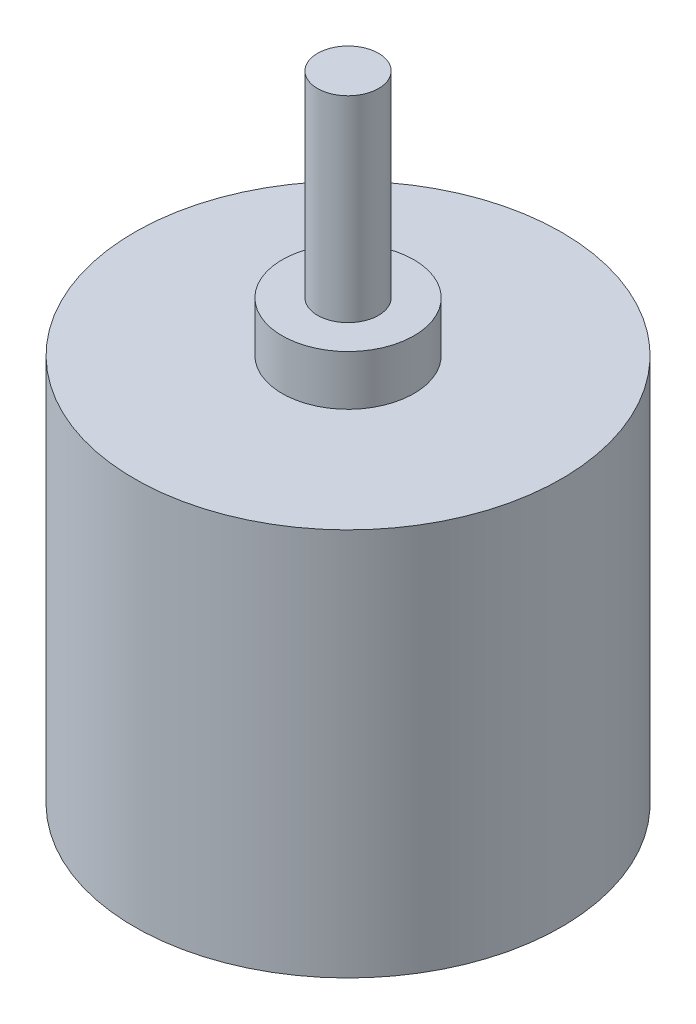
from build123d import *

# Parameters (mm, degrees)
SKETCH2_R          = 1.5
CUT_EXTRUDE1_DEPTH = 5


with BuildPart() as part:
    # Sketch1 → Revolve1 (revolve)
    with BuildSketch(Plane.XY):
        Polygon((0, -26.75), (0, 26.75), (2.5, 26.75), (2.5, 10.65), (5.4, 10.65), (5.4, 6.55), (17.5, 6.55), (17.5, -25.25), (2.5, -25.25), (2.5, -26.75), align=None)
    revolve(axis=Axis((0, -45.789145907, 0), (0, 1, 0)))

    # Sketch2 → Cut-Extrude1 (cut)
    with BuildSketch(Plane.XZ.offset(25.25)):
        with Locations((0, 9.25)):
            Circle(SKETCH2_R)
        with Locations((12, 0)):
            Circle(SKETCH2_R)
        with Locations((0, -9.25)):
            Circle(SKETCH2_R)
        with Locations((-12, 0)):
            Circle(SKETCH2_R)
    extrude(amount=-CUT_EXTRUDE1_DEPTH, mode=Mode.SUBTRACT)


solid = part.part
